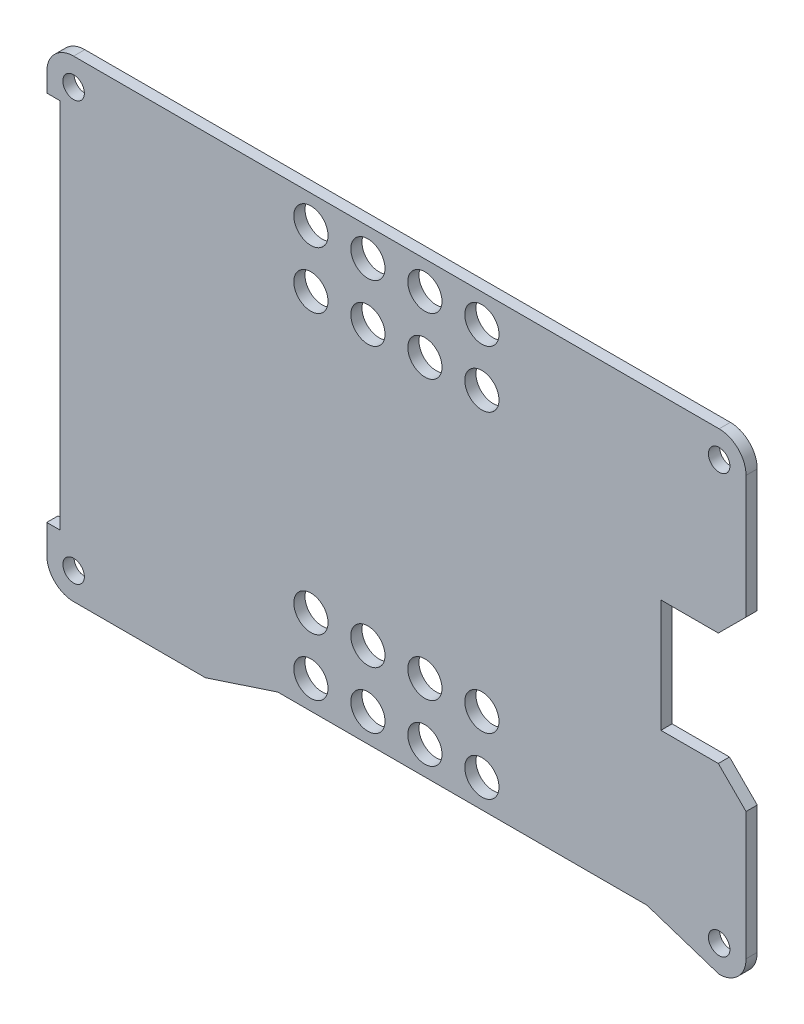
from build123d import *

# Parameters (mm, degrees)
SKETCH1_R           = 1.355900406
BOSS_EXTRUDE1_DEPTH = 1.5875
SKETCH3_R           = 1.524
CUT_EXTRUDE1_DEPTH  = 2.5875
SKETCH5_W           = 2.0955
SKETCH5_H           = 13.208
BOSS_EXTRUDE3_DEPTH = 1.5875
CUT_EXTRUDE2_DEPTH  = 2.5875
SKETCH8_R           = 2.4257
CUT_EXTRUDE3_DEPTH  = 2.5875


with BuildPart() as part:
    # Sketch1 → Boss-Extrude1 (new body)
    with BuildSketch(Plane.XY):
        with BuildLine():
            Line((-301.9473, 111.74645), (-305.87795, 115.6771))
            Line((-305.87795, 115.6771), (-316.1078, 115.6771))
            Line((-316.1078, 115.6771), (-316.1078, 128.8851))
            Line((-316.1078, 128.8851), (-305.87795, 128.8851))
            Line((-305.87795, 128.8851), (-301.9473, 132.81575))
            Line((-301.9473, 132.81575), (-301.9473, 150.9704))
            ThreePointArc((-301.9473, 150.9704), (-303.063223164, 153.664476836), (-305.7573, 154.7804))
            Line((-305.7573, 154.7804), (-397.247125, 154.7804))
            ThreePointArc((-397.247125, 154.7804), (-399.946077222, 153.659592612), (-401.0571, 150.956597849))
            Line((-401.0571, 150.956597849), (-401.0571, 148.341))
            Line((-401.0571, 148.341), (-399.1521, 148.341))
            Line((-399.1521, 148.341), (-399.1521, 95.6449))
            Line((-399.1521, 95.6449), (-401.0571, 95.6449))
            Line((-401.0571, 95.6449), (-401.0571, 91.659304166))
            ThreePointArc((-401.0571, 91.659304166), (-399.951018769, 88.947400452), (-397.2472, 87.8217))
            Line((-397.2472, 87.8217), (-378.5565, 87.8217))
            Line((-378.5565, 87.8217), (-368.3165, 91.1883))
            Line((-368.3165, 91.1883), (-315.9973, 91.1883))
            Line((-315.9973, 91.1883), (-305.7573, 87.8217))
            ThreePointArc((-305.7573, 87.8217), (-303.063223164, 88.937623164), (-301.9473, 91.6317))
            Line((-301.9473, 91.6317), (-301.9473, 111.74645))
        make_face()
        with Locations((-305.7573, 91.6317)):
            Circle(SKETCH1_R, mode=Mode.SUBTRACT)
        with Locations((-305.7573, 150.9704)):
            Circle(SKETCH1_R, mode=Mode.SUBTRACT)
        with Locations((-397.247125, 150.9704)):
            Circle(SKETCH1_R, mode=Mode.SUBTRACT)
        with Locations((-397.2472, 91.6317)):
            Circle(SKETCH1_R, mode=Mode.SUBTRACT)
    extrude(amount=BOSS_EXTRUDE1_DEPTH)

    # Sketch3 → Cut-Extrude1 (cut, through all)
    with BuildSketch(Plane.XY.offset(1.5875)):
        with Locations((-397.247125, 150.9704)):
            Circle(SKETCH3_R)
        with Locations((-305.7573, 150.9704)):
            Circle(SKETCH3_R)
        with Locations((-305.7573, 91.6317)):
            Circle(SKETCH3_R)
        with Locations((-397.2472, 91.6317)):
            Circle(SKETCH3_R)
    extrude(amount=-CUT_EXTRUDE1_DEPTH, mode=Mode.SUBTRACT)

    # Sketch5 → Boss-Extrude3 (add)
    with BuildSketch(Plane.XY.offset(1.5875)):
        with Locations((-315.06005, 122.2811)):
            Rectangle(SKETCH5_W, SKETCH5_H)
    extrude(amount=-BOSS_EXTRUDE3_DEPTH)

    # Sketch4 → Cut-Extrude2 (cut, through all)
    with BuildSketch(Plane.XY.offset(1.5875)):
        Polygon((-301.9473, 133.571034757), (-305.87795, 129.6471), (-314.0123, 129.6471), (-314.0123, 113.6451), (-305.87795, 113.6451), (-301.9473, 109.71445), align=None)
    extrude(amount=-CUT_EXTRUDE2_DEPTH, mode=Mode.SUBTRACT)

    # Sketch8 → Cut-Extrude3 (cut, through all)
    with BuildSketch(Plane.XY.offset(1.5875)):
        with Locations((-363.6180125, 150.7799)):
            Circle(SKETCH8_R)
        with Locations((-355.5408125, 150.7799)):
            Circle(SKETCH8_R)
        with Locations((-347.4636125, 150.7799)):
            Circle(SKETCH8_R)
        with Locations((-339.3864125, 150.7799)):
            Circle(SKETCH8_R)
        with Locations((-339.3864125, 142.7027)):
            Circle(SKETCH8_R)
        with Locations((-347.4636125, 142.7027)):
            Circle(SKETCH8_R)
        with Locations((-355.5408125, 142.7027)):
            Circle(SKETCH8_R)
        with Locations((-363.6180125, 142.7027)):
            Circle(SKETCH8_R)
        with Locations((-363.6180125, 95.1888)):
            Circle(SKETCH8_R)
        with Locations((-339.3864125, 95.1888)):
            Circle(SKETCH8_R)
        with Locations((-347.4636125, 95.1888)):
            Circle(SKETCH8_R)
        with Locations((-355.5408125, 95.1888)):
            Circle(SKETCH8_R)
        with Locations((-363.6180125, 103.266)):
            Circle(SKETCH8_R)
        with Locations((-355.5408125, 103.266)):
            Circle(SKETCH8_R)
        with Locations((-347.4636125, 103.266)):
            Circle(SKETCH8_R)
        with Locations((-339.3864125, 103.266)):
            Circle(SKETCH8_R)
    extrude(amount=-CUT_EXTRUDE3_DEPTH, mode=Mode.SUBTRACT)


solid = part.part
